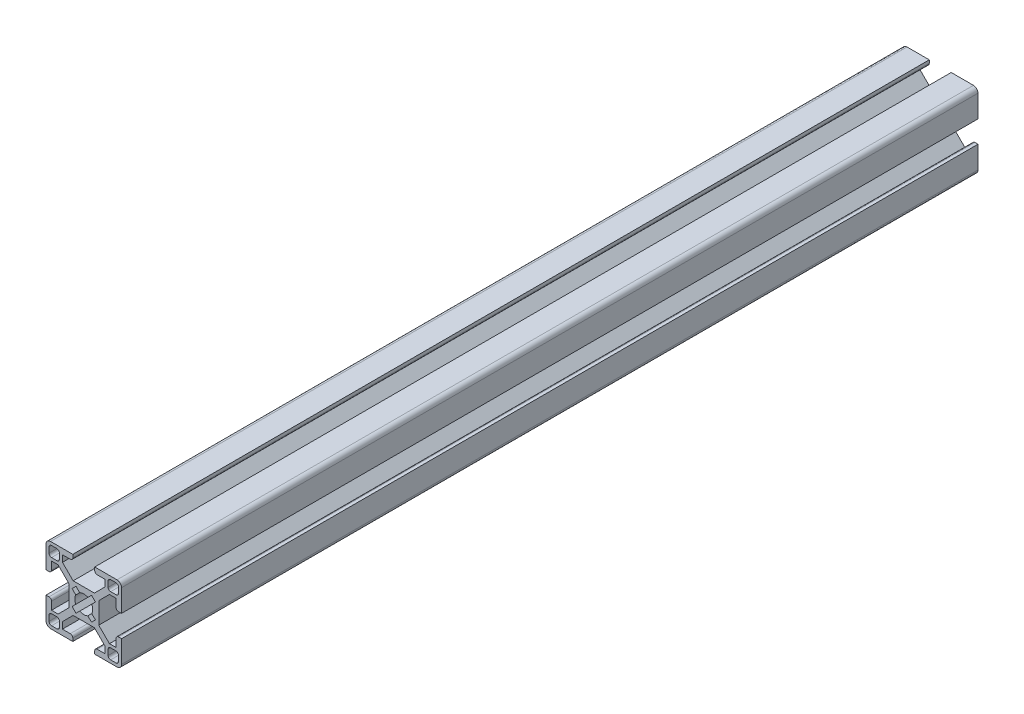
from build123d import *

# Parameters (mm, degrees)
SKETCH1_W           = 11.9
SKETCH1_H           = 5.95
BOSS_EXTRUDE1_DEPTH = 340
CUT_EXTRUDE1_DEPTH  = 341


with BuildPart() as part:
    # Sketch1 → Boss-Extrude1 (new body)
    with BuildSketch(Plane.XY):
        with BuildLine():
            Line((-4.350229073, 14.992640687), (-13.192640687, 14.992640687))
            ThreePointArc((-13.192640687, 14.992640687), (-14.465432893, 14.465432893), (-14.992640687, 13.192640687))
            Line((-14.992640687, 13.192640687), (-14.992640687, 4.350229073))
            Line((-14.992640687, 4.350229073), (-13.792640687, 4.350229073))
            ThreePointArc((-13.792640687, 4.350229073), (-13.085533906, 4.643122292), (-12.792640687, 5.350229073))
            Line((-12.792640687, 5.350229073), (-12.792640687, 8.460229073))
            Line((-12.792640687, 8.460229073), (-8.460229073, 8.460229073))
            Line((-8.460229073, 8.460229073), (-8.460229073, 12.792640687))
            Line((-8.460229073, 12.792640687), (-5.350229073, 12.792640687))
            ThreePointArc((-5.350229073, 12.792640687), (-4.643122292, 13.085533906), (-4.350229073, 13.792640687))
            Line((-4.350229073, 13.792640687), (-4.350229073, 14.992640687))
        make_face()
        with BuildLine():
            Line((-10.660229073, 13.792640687), (-12.792640687, 13.792640687))
            ThreePointArc((-12.792640687, 13.792640687), (-13.499747468, 13.499747468), (-13.792640687, 12.792640687))
            Line((-13.792640687, 12.792640687), (-13.792640687, 10.660229073))
            ThreePointArc((-13.792640687, 10.660229073), (-13.499747468, 9.953122292), (-12.792640687, 9.660229073))
            Line((-12.792640687, 9.660229073), (-10.660229073, 9.660229073))
            ThreePointArc((-10.660229073, 9.660229073), (-9.953122292, 9.953122292), (-9.660229073, 10.660229073))
            Line((-9.660229073, 10.660229073), (-9.660229073, 12.792640687))
            ThreePointArc((-9.660229073, 12.792640687), (-9.953122292, 13.499747468), (-10.660229073, 13.792640687))
        make_face(mode=Mode.SUBTRACT)
        Polygon((-5.95, 4.217588386), (-5.95, 5.95), (-4.217588386, 5.95), (-8.460229073, 10.192640687), (-8.460229073, 8.460229073), (-10.192640687, 8.460229073), align=None)
        with Locations((0, 2.975)):
            Rectangle(SKETCH1_W, SKETCH1_H)
        Polygon((8.460229073, 10.192640687), (4.217588386, 5.95), (5.95, 5.95), (5.95, 4.217588386), (10.192640687, 8.460229073), (8.460229073, 8.460229073), align=None)
        with BuildLine():
            Line((12.792640687, 8.460229073), (12.792640687, 5.350229073))
            ThreePointArc((12.792640687, 5.350229073), (13.085533906, 4.643122292), (13.792640687, 4.350229073))
            Line((13.792640687, 4.350229073), (14.992640687, 4.350229073))
            Line((14.992640687, 4.350229073), (14.992640687, 13.192640687))
            ThreePointArc((14.992640687, 13.192640687), (14.465432893, 14.465432893), (13.192640687, 14.992640687))
            Line((13.192640687, 14.992640687), (4.350229073, 14.992640687))
            Line((4.350229073, 14.992640687), (4.350229073, 13.792640687))
            ThreePointArc((4.350229073, 13.792640687), (4.643122292, 13.085533906), (5.350229073, 12.792640687))
            Line((5.350229073, 12.792640687), (8.460229073, 12.792640687))
            Line((8.460229073, 12.792640687), (8.460229073, 8.460229073))
            Line((8.460229073, 8.460229073), (12.792640687, 8.460229073))
        make_face()
        with BuildLine():
            ThreePointArc((9.660229073, 10.660229073), (9.953122292, 9.953122292), (10.660229073, 9.660229073))
            Line((10.660229073, 9.660229073), (12.792640687, 9.660229073))
            ThreePointArc((12.792640687, 9.660229073), (13.499747468, 9.953122292), (13.792640687, 10.660229073))
            Line((13.792640687, 10.660229073), (13.792640687, 12.792640687))
            ThreePointArc((13.792640687, 12.792640687), (13.499747468, 13.499747468), (12.792640687, 13.792640687))
            Line((12.792640687, 13.792640687), (10.660229073, 13.792640687))
            ThreePointArc((10.660229073, 13.792640687), (9.953122292, 13.499747468), (9.660229073, 12.792640687))
            Line((9.660229073, 12.792640687), (9.660229073, 10.660229073))
        make_face(mode=Mode.SUBTRACT)
    extrude(amount=-BOSS_EXTRUDE1_DEPTH)

    # Mirror1: part across plane


with BuildPart() as part_1:
    add(part.part)
    add(part.part.mirror(Plane(origin=(0, 0, -340), x_dir=(0, 0, 1), z_dir=(0, -1, 0))))

    # Sketch2 → Cut-Extrude1 (cut, through all)
    with BuildSketch(Plane.XY):
        with BuildLine():
            Line((-4.631549417, 3.075914498), (-3.16821753, 1.612582612))
            ThreePointArc((-3.16821753, 1.612582612), (-2.513764607, 2.513764607), (-1.612582612, 3.16821753))
            Line((-1.612582612, 3.16821753), (-3.075914498, 4.631549417))
            Line((-3.075914498, 4.631549417), (-4.631549417, 3.075914498))
        make_face()
        with BuildLine():
            Line((-3.16821753, 1.612582612), (-1.555634919, 0))
            Line((-1.555634919, 0), (0, 1.555634919))
            Line((0, 1.555634919), (-1.612582612, 3.16821753))
            ThreePointArc((-1.612582612, 3.16821753), (-2.513764607, 2.513764607), (-3.16821753, 1.612582612))
        make_face()
        with BuildLine():
            ThreePointArc((-3.16821753, 1.612582612), (-3.555, 0), (-3.16821753, -1.612582612))
            Line((-3.16821753, -1.612582612), (-1.555634919, 0))
            Line((-1.555634919, 0), (-3.16821753, 1.612582612))
        make_face()
        with BuildLine():
            Line((-4.631549417, -3.075914498), (-3.075914498, -4.631549417))
            Line((-3.075914498, -4.631549417), (-1.612582612, -3.16821753))
            ThreePointArc((-1.612582612, -3.16821753), (-2.513764607, -2.513764607), (-3.16821753, -1.612582612))
            Line((-3.16821753, -1.612582612), (-4.631549417, -3.075914498))
        make_face()
        with BuildLine():
            ThreePointArc((-3.16821753, -1.612582612), (-2.513764607, -2.513764607), (-1.612582612, -3.16821753))
            Line((-1.612582612, -3.16821753), (0, -1.555634919))
            Line((0, -1.555634919), (-1.555634919, 0))
            Line((-1.555634919, 0), (-3.16821753, -1.612582612))
        make_face()
        with BuildLine():
            Line((0, -1.555634919), (-1.612582612, -3.16821753))
            ThreePointArc((-1.612582612, -3.16821753), (0, -3.555), (1.612582612, -3.16821753))
            Line((1.612582612, -3.16821753), (0, -1.555634919))
        make_face()
        with BuildLine():
            Line((1.555634919, 0), (0, -1.555634919))
            Line((0, -1.555634919), (1.612582612, -3.16821753))
            ThreePointArc((1.612582612, -3.16821753), (2.513764607, -2.513764607), (3.16821753, -1.612582612))
            Line((3.16821753, -1.612582612), (1.555634919, 0))
        make_face()
        with BuildLine():
            Line((3.16821753, 1.612582612), (1.555634919, 0))
            Line((1.555634919, 0), (3.16821753, -1.612582612))
            ThreePointArc((3.16821753, -1.612582612), (3.456952294, -0.829159719), (3.555, 0))
            ThreePointArc((3.555, 0), (3.456952294, 0.829159719), (3.16821753, 1.612582612))
        make_face()
        Polygon((-1.555634919, 0), (0, -1.555634919), (1.555634919, 0), (0, 1.555634919), align=None)
        with BuildLine():
            Line((0, 1.555634919), (1.555634919, 0))
            Line((1.555634919, 0), (3.16821753, 1.612582612))
            ThreePointArc((3.16821753, 1.612582612), (2.513764607, 2.513764607), (1.612582612, 3.16821753))
            Line((1.612582612, 3.16821753), (0, 1.555634919))
        make_face()
        with BuildLine():
            Line((-1.612582612, 3.16821753), (0, 1.555634919))
            Line((0, 1.555634919), (1.612582612, 3.16821753))
            ThreePointArc((1.612582612, 3.16821753), (0, 3.555), (-1.612582612, 3.16821753))
        make_face()
        with BuildLine():
            ThreePointArc((1.612582612, 3.16821753), (2.513764607, 2.513764607), (3.16821753, 1.612582612))
            Line((3.16821753, 1.612582612), (4.631549417, 3.075914498))
            Line((4.631549417, 3.075914498), (3.075914498, 4.631549417))
            Line((3.075914498, 4.631549417), (1.612582612, 3.16821753))
        make_face()
        with BuildLine():
            ThreePointArc((3.16821753, -1.612582612), (2.513764607, -2.513764607), (1.612582612, -3.16821753))
            Line((1.612582612, -3.16821753), (3.075914498, -4.631549417))
            Line((3.075914498, -4.631549417), (4.631549417, -3.075914498))
            Line((4.631549417, -3.075914498), (3.16821753, -1.612582612))
        make_face()
    extrude(amount=-CUT_EXTRUDE1_DEPTH, mode=Mode.SUBTRACT)


solid = part_1.part
